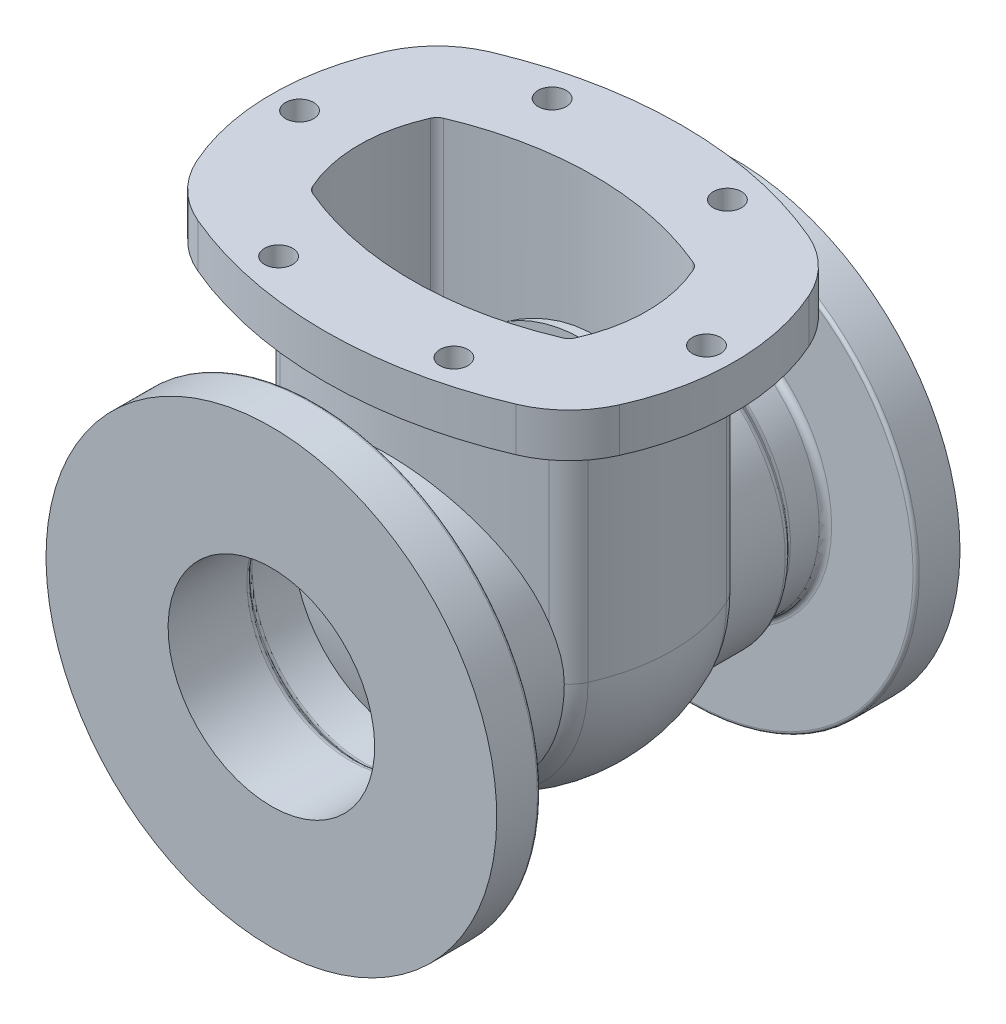
from build123d import *

# Parameters (mm, degrees)
SKETCH6_R           = 7.14375
BOSS_EXTRUDE1_DEPTH = 22.225
BOSS_EXTRUDE4_DEPTH = 120.65
REVOLVE3_ANGLE      = 180


with BuildPart() as part:
    # Sketch1 → Revolve1 (revolve)
    with BuildSketch(Plane(origin=(0, 0, 0), x_dir=(0, 0, -1), z_dir=(1, 0, 0))):
        with BuildLine():
            Line((-77.515128061, -52.3875), (-117.475, -52.3875))
            Line((-117.475, -52.3875), (-117.475, -114.3))
            Line((-117.475, -114.3), (-96.8375, -114.3))
            ThreePointArc((-96.8375, -114.3), (-95.714967985, -113.835032015), (-95.25, -112.7125))
            Line((-95.25, -112.7125), (-95.25, -71.4375))
            ThreePointArc((-95.25, -71.4375), (-94.32006403, -69.19243597), (-92.075, -68.2625))
            Line((-92.075, -68.2625), (-77.515128061, -68.2625))
            ThreePointArc((-77.515128061, -68.2625), (-76.300108163, -68.504182484), (-75.27006403, -69.19243597))
            Line((-75.27006403, -69.19243597), (-72.36743597, -72.09506403))
            ThreePointArc((-72.36743597, -72.09506403), (-71.337391837, -72.783317516), (-70.122371939, -73.025))
            Line((-70.122371939, -73.025), (-41.275, -73.025))
            Line((-41.275, -73.025), (-41.275, -57.15))
            Line((-41.275, -57.15), (-70.122371939, -57.15))
            ThreePointArc((-70.122371939, -57.15), (-71.337391837, -56.908317516), (-72.36743597, -56.22006403))
            Line((-72.36743597, -56.22006403), (-75.27006403, -53.31743597))
            ThreePointArc((-75.27006403, -53.31743597), (-76.300108163, -52.629182484), (-77.515128061, -52.3875))
        make_face()
        with BuildLine():
            Line((70.122371939, -57.15), (41.275, -57.15))
            Line((41.275, -57.15), (41.275, -73.025))
            Line((41.275, -73.025), (70.122371939, -73.025))
            ThreePointArc((70.122371939, -73.025), (71.337391837, -72.783317516), (72.36743597, -72.09506403))
            Line((72.36743597, -72.09506403), (75.27006403, -69.19243597))
            ThreePointArc((75.27006403, -69.19243597), (76.300108163, -68.504182484), (77.515128061, -68.2625))
            Line((77.515128061, -68.2625), (92.075, -68.2625))
            ThreePointArc((92.075, -68.2625), (94.32006403, -69.19243597), (95.25, -71.4375))
            Line((95.25, -71.4375), (95.25, -112.7125))
            ThreePointArc((95.25, -112.7125), (95.714967985, -113.835032015), (96.8375, -114.3))
            Line((96.8375, -114.3), (117.475, -114.3))
            Line((117.475, -114.3), (117.475, -52.3875))
            Line((117.475, -52.3875), (77.515128061, -52.3875))
            ThreePointArc((77.515128061, -52.3875), (76.300108163, -52.629182484), (75.27006403, -53.31743597))
            Line((75.27006403, -53.31743597), (72.36743597, -56.22006403))
            ThreePointArc((72.36743597, -56.22006403), (71.337391837, -56.908317516), (70.122371939, -57.15))
        make_face()
    revolve(axis=Axis((0, 0, 117.475), (0, 0, -1)))



with BuildPart() as body_2:
    # Sketch6 → Boss-Extrude1 (new body)
    with BuildSketch(Plane(origin=(0, 142.875, 0), x_dir=(1, 0, 0), z_dir=(0, 1, 0))):
        with BuildLine():
            ThreePointArc((-107.174095369, -48.104977984), (-117.475, 0), (-107.174095369, 48.104977984))
            ThreePointArc((-107.174095369, 48.104977984), (-96.385165084, 63.584590133), (-80.690921224, 74.058849944))
            ThreePointArc((-80.690921224, 74.058849944), (0, 90.4875), (80.690921224, 74.058849944))
            ThreePointArc((80.690921224, 74.058849944), (96.385165084, 63.584590133), (107.174095369, 48.104977984))
            ThreePointArc((107.174095369, 48.104977984), (117.475, 0), (107.174095369, -48.104977984))
            ThreePointArc((107.174095369, -48.104977984), (96.385165084, -63.584590133), (80.690921224, -74.058849944))
            ThreePointArc((80.690921224, -74.058849944), (0, -90.4875), (-80.690921224, -74.058849944))
            ThreePointArc((-80.690921224, -74.058849944), (-96.385165084, -63.584590133), (-107.174095369, -48.104977984))
        make_face()
        with Locations(Location((-44.45, 69.354092252, 0), (0, 0, 270))):
            Circle(SKETCH6_R, mode=Mode.SUBTRACT)
        with Locations(Location((44.45, 69.354092252, 0), (0, 0, 270))):
            Circle(SKETCH6_R, mode=Mode.SUBTRACT)
        with Locations(Location((-44.45, -69.354092252, 0), (0, 0, 270))):
            Circle(SKETCH6_R, mode=Mode.SUBTRACT)
        with Locations(Location((44.45, -69.354092252, 0), (0, 0, 270))):
            Circle(SKETCH6_R, mode=Mode.SUBTRACT)
        with Locations(Location((103.1875, 0, 0), (0, 0, 270))):
            Circle(SKETCH6_R, mode=Mode.SUBTRACT)
        with Locations(Location((-103.1875, 0, 0), (0, 0, 270))):
            Circle(SKETCH6_R, mode=Mode.SUBTRACT)
        with BuildLine():
            ThreePointArc((63.311338191, 33.147328418), (0, 46.0375), (-63.311338191, 33.147328418))
            ThreePointArc((-63.311338191, 33.147328418), (-65.273118673, 31.838045941), (-66.621734959, 29.903094423))
            ThreePointArc((-66.621734959, 29.903094423), (-73.025, 0), (-66.621734959, -29.903094423))
            ThreePointArc((-66.621734959, -29.903094423), (-65.273118673, -31.838045941), (-63.311338191, -33.147328418))
            ThreePointArc((-63.311338191, -33.147328418), (0, -46.0375), (63.311338191, -33.147328418))
            ThreePointArc((63.311338191, -33.147328418), (65.273118673, -31.838045941), (66.621734959, -29.903094423))
            ThreePointArc((66.621734959, -29.903094423), (73.025, 0), (66.621734959, 29.903094423))
            ThreePointArc((66.621734959, 29.903094423), (65.273118673, 31.838045941), (63.311338191, 33.147328418))
        make_face(mode=Mode.SUBTRACT)
    extrude(amount=-BOSS_EXTRUDE1_DEPTH)

    # Sketch7 → Boss-Extrude4 (add)
    with BuildSketch(Plane.XZ.offset(-120.65)):
        with BuildLine():
            ThreePointArc((68.276933343, 44.836334568), (0, 58.7375), (-68.276933343, 44.836334568))
            ThreePointArc((-68.276933343, 44.836334568), (-74.162274791, 40.908487139), (-78.208123648, 35.103632583))
            ThreePointArc((-78.208123648, 35.103632583), (-85.725, 0), (-78.208123648, -35.103632583))
            ThreePointArc((-78.208123648, -35.103632583), (-74.162274791, -40.908487139), (-68.276933343, -44.836334568))
            ThreePointArc((-68.276933343, -44.836334568), (0, -58.7375), (68.276933343, -44.836334568))
            ThreePointArc((68.276933343, -44.836334568), (74.162274791, -40.908487139), (78.208123648, -35.103632583))
            ThreePointArc((78.208123648, -35.103632583), (85.725, 0), (78.208123648, 35.103632583))
            ThreePointArc((78.208123648, 35.103632583), (74.162274791, 40.908487139), (68.276933343, 44.836334568))
        make_face()
        with BuildLine():
            ThreePointArc((-63.311338191, 33.147328418), (-65.273118673, 31.838045941), (-66.621734959, 29.903094423))
            ThreePointArc((-66.621734959, 29.903094423), (-73.025, 0), (-66.621734959, -29.903094423))
            ThreePointArc((-66.621734959, -29.903094423), (-65.273118673, -31.838045941), (-63.311338191, -33.147328418))
            ThreePointArc((-63.311338191, -33.147328418), (0, -46.0375), (63.311338191, -33.147328418))
            ThreePointArc((63.311338191, -33.147328418), (65.273118673, -31.838045941), (66.621734959, -29.903094423))
            ThreePointArc((66.621734959, -29.903094423), (73.025, 0), (66.621734959, 29.903094423))
            ThreePointArc((66.621734959, 29.903094423), (65.273118673, 31.838045941), (63.311338191, 33.147328418))
            ThreePointArc((63.311338191, 33.147328418), (0, 46.0375), (-63.311338191, 33.147328418))
        make_face(mode=Mode.SUBTRACT)
    extrude(amount=BOSS_EXTRUDE4_DEPTH)


with BuildPart() as part_1:
    add(part.part)

    add(body_2.part)  # Revolve3 merges body 2
    # Sketch11 → Revolve3 (revolve)
    with BuildSketch(Plane.XZ):
        with BuildLine():
            ThreePointArc((68.276933343, 44.836334568), (34.838850538, 55.226921129), (0, 58.7375))
            Line((0, 58.7375), (0, 46.0375))
            ThreePointArc((0, 46.0375), (32.305115953, 42.782235956), (63.311338191, 33.147328418))
            ThreePointArc((63.311338191, 33.147328418), (65.273118673, 31.838045941), (66.621734959, 29.903094423))
            ThreePointArc((66.621734959, 29.903094423), (73.025, 0), (66.621734959, -29.903094423))
            ThreePointArc((66.621734959, -29.903094423), (65.273118673, -31.838045941), (63.311338191, -33.147328418))
            ThreePointArc((63.311338191, -33.147328418), (32.305115953, -42.782235956), (0, -46.0375))
            Line((0, -46.0375), (0, -58.7375))
            ThreePointArc((0, -58.7375), (34.838850538, -55.226921129), (68.276933343, -44.836334568))
            ThreePointArc((68.276933343, -44.836334568), (74.162274791, -40.908487139), (78.208123648, -35.103632583))
            ThreePointArc((78.208123648, -35.103632583), (85.725, 0), (78.208123648, 35.103632583))
            ThreePointArc((78.208123648, 35.103632583), (74.162274791, 40.908487139), (68.276933343, 44.836334568))
        make_face()
    revolve(axis=Axis((0, 0, 58.7375), (0, 0, -1)), revolution_arc=REVOLVE3_ANGLE)


solid = part_1.part
